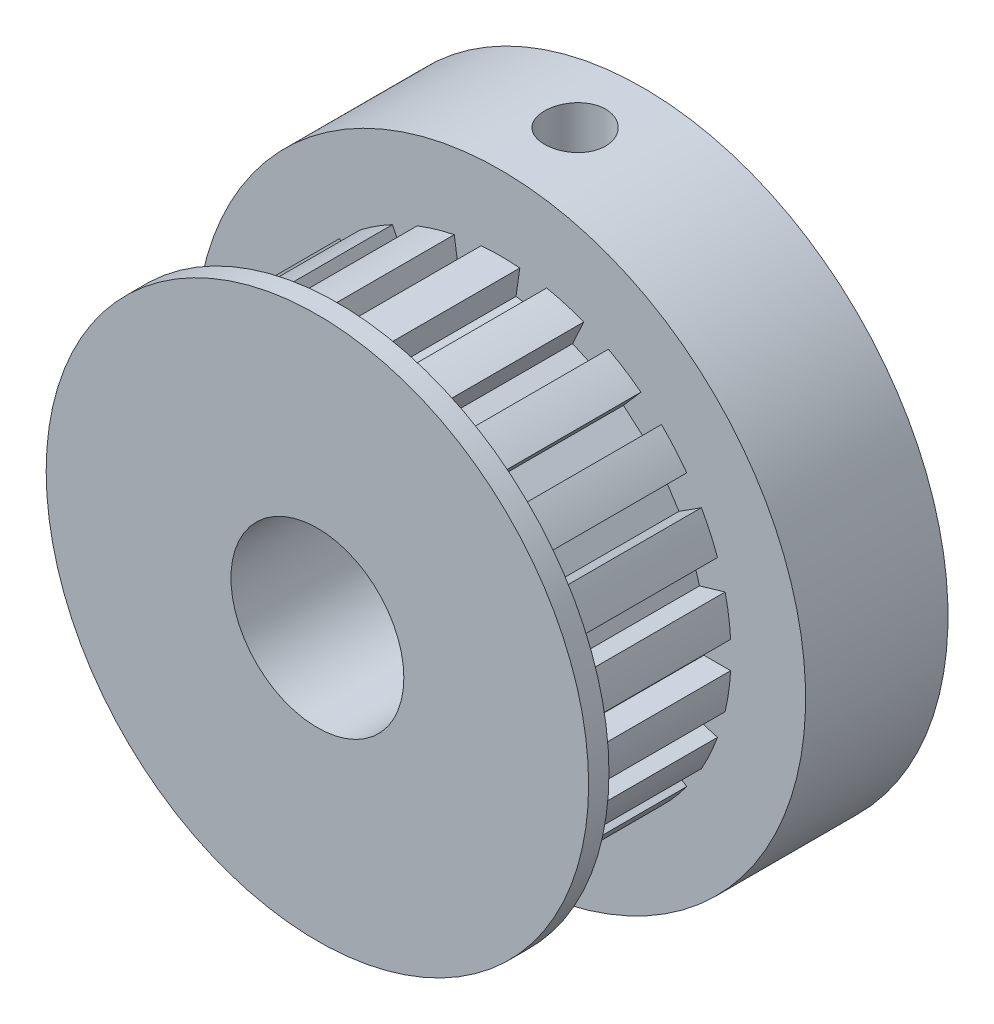
from build123d import *

# Parameters (mm, degrees)
SKETCH1_R               = 10.16
BOSS_EXTRUDE1_DEPTH     = 0.762
SKETCH2_R               = 8.636
BOSS_EXTRUDE2_DEPTH     = 6.096
SKETCH3_R               = 11.43
BOSS_EXTRUDE3_DEPTH     = 5.334
SKETCH4_R               = 3.2385
CUT_EXTRUDE1_DEPTH      = 25.654
SKETCH5_W               = 6.096
SKETCH5_H               = 1.016
CUT_EXTRUDE2_DEPTH      = 1.016
CIRPATTERN1_COUNT       = 22
CUT_EXTRUDE3_DEPTH      = 22.098
CUT_EXTRUDE3_DEPTH_BACK = 22.098
SKETCH6_R               = 1.143


with BuildPart() as part:
    # Sketch1 → Boss-Extrude1 (new body)
    with BuildSketch(Plane.XY):
        Circle(SKETCH1_R)
    extrude(amount=-BOSS_EXTRUDE1_DEPTH)

    # Sketch2 → Boss-Extrude2 (add)
    with BuildSketch(Plane(origin=(0, 0, -0.762), x_dir=(-1, 0, 0), z_dir=(0, 0, -1))):
        Circle(SKETCH2_R)
    extrude(amount=BOSS_EXTRUDE2_DEPTH)

    # Sketch3 → Boss-Extrude3 (add)
    with BuildSketch(Plane(origin=(0, 0, -6.858), x_dir=(-1, 0, 0), z_dir=(0, 0, -1))):
        Circle(SKETCH3_R)
    extrude(amount=BOSS_EXTRUDE3_DEPTH)

    # Sketch4 → Cut-Extrude1 (cut)
    with BuildSketch(Plane.XY):
        Circle(SKETCH4_R)
    extrude(amount=-CUT_EXTRUDE1_DEPTH, mode=Mode.SUBTRACT)

    # Sketch5 → Cut-Extrude2 (cut)
    with BuildSketch(Plane.ZY.offset(8.636)):
        with Locations((-3.81, 0)):
            Rectangle(SKETCH5_W, SKETCH5_H)
    cut_extrude2 = extrude(amount=-CUT_EXTRUDE2_DEPTH, mode=Mode.SUBTRACT)

    # CirPattern1: Cut-Extrude2 ×22 about axis
    cirpattern1_axis = Axis((0, 0, -12.192), (0, 0, 1))
    for i in range(1, CIRPATTERN1_COUNT):
        add(cut_extrude2.rotate(cirpattern1_axis, i * 360 / CIRPATTERN1_COUNT), mode=Mode.SUBTRACT)

    # Sketch6 → Cut-Extrude3 (cut, two sides: drawn at the far end of the back side and taken through both)
    with BuildSketch(Plane(origin=(0, 0, 0), x_dir=(1, 0, 0), z_dir=(0, 1, 0)).offset(-CUT_EXTRUDE3_DEPTH_BACK)):
        with Locations((0, 9.652)):
            Circle(SKETCH6_R)
    extrude(amount=CUT_EXTRUDE3_DEPTH + CUT_EXTRUDE3_DEPTH_BACK, mode=Mode.SUBTRACT)


solid = part.part
